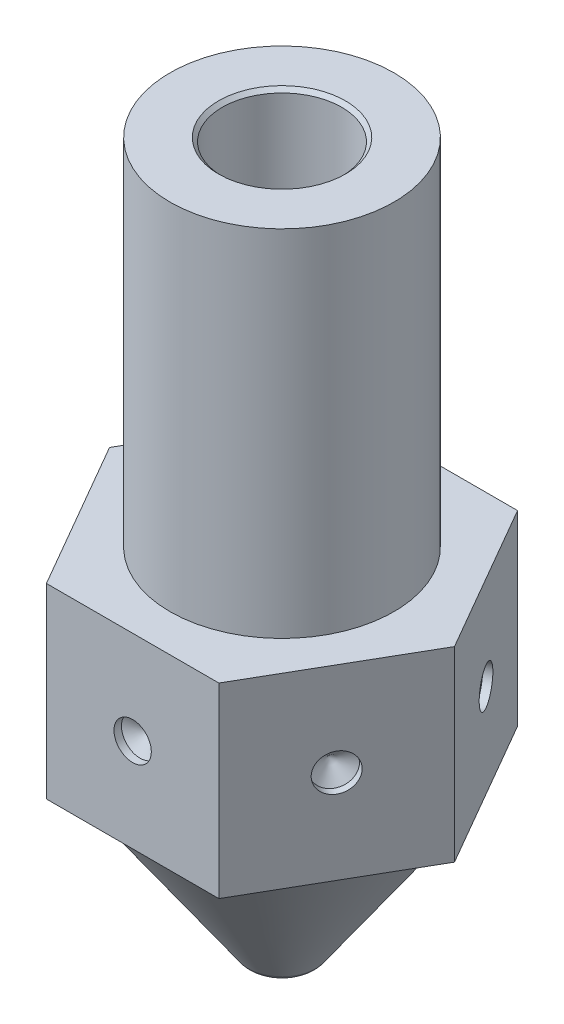
from build123d import *

# Parameters (mm, degrees)
CORTAR_EXTRUIR1_START                       = 1
CROQUIS2_R                                  = 7.435198433
CORTAR_EXTRUIR1_DEPTH                       = 7
CHAFL_N1_SIZE                               = 0.1
DI_METRO_DE_TALADRO_1_0_1_1_D               = 1
DI_METRO_DE_TALADRO_1_0_1_1_DEPTH           = 0.2
DI_METRO_DE_TALADRO_1_0_1_1_TIP             = 0.30043031
DI_METRO_DE_TALADRO_1_0_1_1_ON_FACE_2_D     = 1
DI_METRO_DE_TALADRO_1_0_1_1_ON_FACE_2_DEPTH = 0.2
DI_METRO_DE_TALADRO_1_0_1_1_ON_FACE_2_TIP   = 0.30043031
DI_METRO_DE_TALADRO_1_0_1_1_ON_FACE_3_D     = 1
DI_METRO_DE_TALADRO_1_0_1_1_ON_FACE_3_DEPTH = 0.2
DI_METRO_DE_TALADRO_1_0_1_1_ON_FACE_3_TIP   = 0.30043031
DI_METRO_DE_TALADRO_1_0_1_1_ON_FACE_4_D     = 1
DI_METRO_DE_TALADRO_1_0_1_1_ON_FACE_4_DEPTH = 0.2
DI_METRO_DE_TALADRO_1_0_1_1_ON_FACE_4_TIP   = 0.30043031
DI_METRO_DE_TALADRO_1_0_1_1_ON_FACE_5_D     = 1
DI_METRO_DE_TALADRO_1_0_1_1_ON_FACE_5_DEPTH = 0.2
DI_METRO_DE_TALADRO_1_0_1_1_ON_FACE_5_TIP   = 0.30043031
DI_METRO_DE_TALADRO_1_0_1_1_ON_FACE_6_D     = 1
DI_METRO_DE_TALADRO_1_0_1_1_ON_FACE_6_DEPTH = 0.2
DI_METRO_DE_TALADRO_1_0_1_1_ON_FACE_6_TIP   = 0.30043031


with BuildPart() as part:
    # Croquis1 → Revolución1 (revolve)
    with BuildSketch(Plane.XY):
        with BuildLine():
            Line((0.5, 0), (0.575, 0))
            ThreePointArc((0.575, 0), (0.759699445, 0.045195667), (0.902660818, 0.170569425))
            Line((0.902660818, 0.170569425), (3.934160742, 4.5))
            Line((3.934160742, 4.5), (6.64058638, 4.5))
            Line((6.64058638, 4.5), (6.64058638, 8.36517638))
            Line((6.64058638, 8.36517638), (7.435198433, 9.5))
            Line((7.435198433, 9.5), (3, 9.5))
            Line((3, 9.5), (3, 19))
            Line((3, 19), (1.6, 19))
            Line((1.6, 19), (1.6, 3.570962807))
            Line((1.6, 3.570962807), (0.5, 2))
            Line((0.5, 2), (0.5, 0))
        make_face()
    revolve(axis=Axis((0, 0, 0), (0, 1, 0)))

    # Croquis2 → Cortar-Extruir1 (cut)
    with BuildSketch(Plane(origin=(0, 9.5, 0), x_dir=(1, 0, 0), z_dir=(0, 1, 0)).offset(CORTAR_EXTRUIR1_START)):
        Circle(CROQUIS2_R)
        Polygon((2.309401077, 4), (-2.309401077, 4), (-4.618802154, 0), (-2.309401077, -4), (2.309401077, -4), (4.618802154, 0), align=None, mode=Mode.SUBTRACT)
    extrude(amount=-CORTAR_EXTRUIR1_DEPTH, mode=Mode.SUBTRACT)

    # Chaflán1
    chafl_n1_edges = [part.edges().sort_by_distance(p)[0] for p in [
        (-1.6, 19, 0),
    ]]
    chamfer(chafl_n1_edges, length=CHAFL_N1_SIZE)

    # Diámetro de taladro Ø1.0 (1)1
    with Locations(Plane(origin=(0, 7, 4), x_dir=(1, 0, 0), z_dir=(0, 0, 1))):
        with Locations((0, 0)):
            Hole(DI_METRO_DE_TALADRO_1_0_1_1_D / 2, depth=DI_METRO_DE_TALADRO_1_0_1_1_DEPTH)
            with Locations((0, 0, -(DI_METRO_DE_TALADRO_1_0_1_1_DEPTH + DI_METRO_DE_TALADRO_1_0_1_1_TIP / 2))):  # 118° drill point
                Cone(0, DI_METRO_DE_TALADRO_1_0_1_1_D / 2, DI_METRO_DE_TALADRO_1_0_1_1_TIP, mode=Mode.SUBTRACT)

    # Diámetro de taladro Ø1.0 (1)1 on face 2
    with Locations(Plane(origin=(3.464101615, 7, 2), x_dir=(-0.500000175, 0, 0.866025303), z_dir=(0.866025303, 0, 0.500000175))):
        with Locations((0, 0)):
            Hole(DI_METRO_DE_TALADRO_1_0_1_1_ON_FACE_2_D / 2, depth=DI_METRO_DE_TALADRO_1_0_1_1_ON_FACE_2_DEPTH)
            with Locations((0, 0, -(DI_METRO_DE_TALADRO_1_0_1_1_ON_FACE_2_DEPTH + DI_METRO_DE_TALADRO_1_0_1_1_ON_FACE_2_TIP / 2))):  # 118° drill point
                Cone(0, DI_METRO_DE_TALADRO_1_0_1_1_ON_FACE_2_D / 2, DI_METRO_DE_TALADRO_1_0_1_1_ON_FACE_2_TIP, mode=Mode.SUBTRACT)

    # Diámetro de taladro Ø1.0 (1)1 on face 3
    with Locations(Plane(origin=(3.464101615, 7, -2), x_dir=(0.500000175, 0, 0.866025303), z_dir=(0.866025303, 0, -0.500000175))):
        with Locations((0, 0)):
            Hole(DI_METRO_DE_TALADRO_1_0_1_1_ON_FACE_3_D / 2, depth=DI_METRO_DE_TALADRO_1_0_1_1_ON_FACE_3_DEPTH)
            with Locations((0, 0, -(DI_METRO_DE_TALADRO_1_0_1_1_ON_FACE_3_DEPTH + DI_METRO_DE_TALADRO_1_0_1_1_ON_FACE_3_TIP / 2))):  # 118° drill point
                Cone(0, DI_METRO_DE_TALADRO_1_0_1_1_ON_FACE_3_D / 2, DI_METRO_DE_TALADRO_1_0_1_1_ON_FACE_3_TIP, mode=Mode.SUBTRACT)

    # Diámetro de taladro Ø1.0 (1)1 on face 4
    with Locations(Plane(origin=(0, 7, -4), x_dir=(-1, 0, 0), z_dir=(0, 0, -1))):
        with Locations((0, 0)):
            Hole(DI_METRO_DE_TALADRO_1_0_1_1_ON_FACE_4_D / 2, depth=DI_METRO_DE_TALADRO_1_0_1_1_ON_FACE_4_DEPTH)
            with Locations((0, 0, -(DI_METRO_DE_TALADRO_1_0_1_1_ON_FACE_4_DEPTH + DI_METRO_DE_TALADRO_1_0_1_1_ON_FACE_4_TIP / 2))):  # 118° drill point
                Cone(0, DI_METRO_DE_TALADRO_1_0_1_1_ON_FACE_4_D / 2, DI_METRO_DE_TALADRO_1_0_1_1_ON_FACE_4_TIP, mode=Mode.SUBTRACT)

    # Diámetro de taladro Ø1.0 (1)1 on face 5
    with Locations(Plane(origin=(-3.464101615, 7, -2), x_dir=(0.500000175, 0, -0.866025303), z_dir=(-0.866025303, 0, -0.500000175))):
        with Locations((0, 0)):
            Hole(DI_METRO_DE_TALADRO_1_0_1_1_ON_FACE_5_D / 2, depth=DI_METRO_DE_TALADRO_1_0_1_1_ON_FACE_5_DEPTH)
            with Locations((0, 0, -(DI_METRO_DE_TALADRO_1_0_1_1_ON_FACE_5_DEPTH + DI_METRO_DE_TALADRO_1_0_1_1_ON_FACE_5_TIP / 2))):  # 118° drill point
                Cone(0, DI_METRO_DE_TALADRO_1_0_1_1_ON_FACE_5_D / 2, DI_METRO_DE_TALADRO_1_0_1_1_ON_FACE_5_TIP, mode=Mode.SUBTRACT)

    # Diámetro de taladro Ø1.0 (1)1 on face 6
    with Locations(Plane(origin=(-3.464101615, 7, 2), x_dir=(-0.500000175, 0, -0.866025303), z_dir=(-0.866025303, 0, 0.500000175))):
        with Locations((0, 0)):
            Hole(DI_METRO_DE_TALADRO_1_0_1_1_ON_FACE_6_D / 2, depth=DI_METRO_DE_TALADRO_1_0_1_1_ON_FACE_6_DEPTH)
            with Locations((0, 0, -(DI_METRO_DE_TALADRO_1_0_1_1_ON_FACE_6_DEPTH + DI_METRO_DE_TALADRO_1_0_1_1_ON_FACE_6_TIP / 2))):  # 118° drill point
                Cone(0, DI_METRO_DE_TALADRO_1_0_1_1_ON_FACE_6_D / 2, DI_METRO_DE_TALADRO_1_0_1_1_ON_FACE_6_TIP, mode=Mode.SUBTRACT)


solid = part.part
